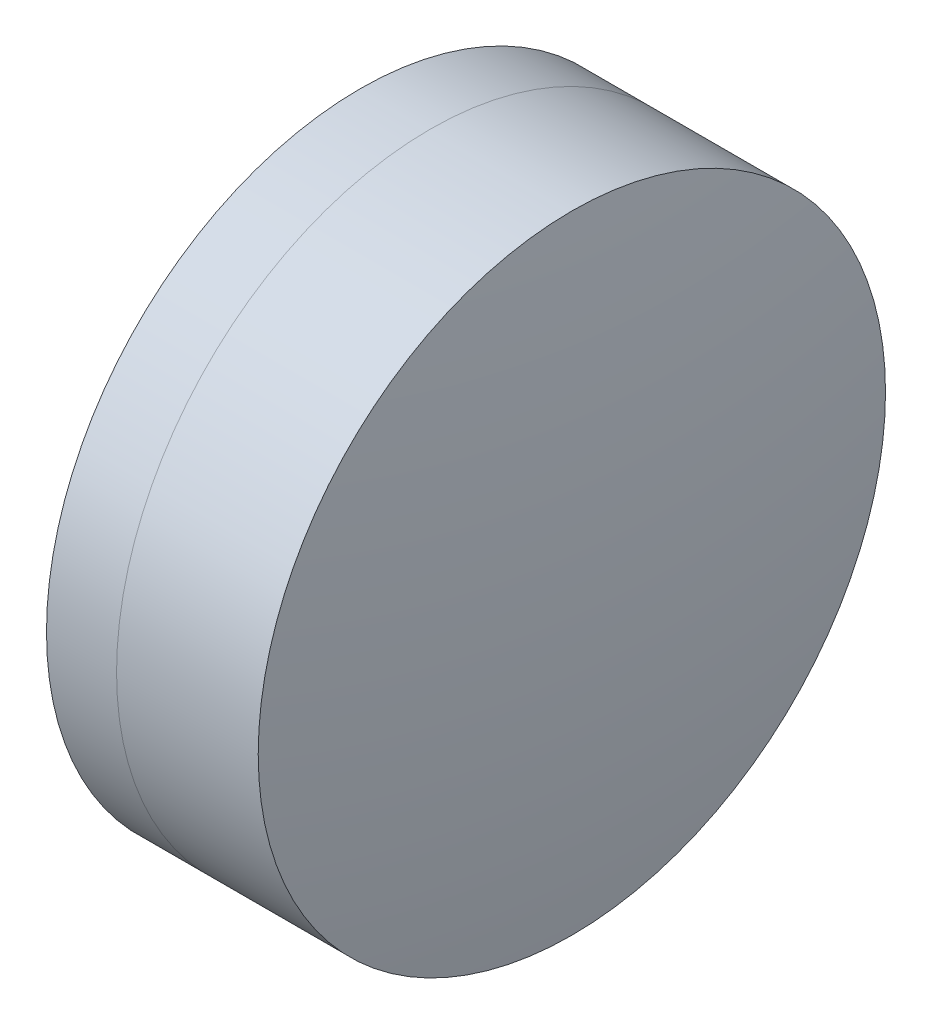
from build123d import *


with BuildPart() as part:
    # 草图1 one side → 旋转1 (revolve)
    with BuildSketch(Plane(origin=(0, 0, 0), x_dir=(1, 0, 0), z_dir=(0, 1, 0)), mode=Mode.PRIVATE) as revolve_1_sk:
        with BuildLine():
            ThreePointArc((2.605354895, 5), (2.014233192, 2.530995807), (1.815570679, 0))
            Line((1.815570679, 0), (4.865570679, 0))
            ThreePointArc((4.865570679, 0), (4.576106633, 2.564523008), (3.722280238, 5))
            Line((3.722280238, 5), (2.605354895, 5))
        make_face()
    revolve(revolve_1_sk.sketch.rotate(Axis((-9.702612178, 0, 0), (1, 0, 0)), 180), axis=Axis((-9.702612178, 0, 0), (1, 0, 0)))  # turned: the seam where the file's is


with BuildPart() as body_2:
    # 草图2 one side → 旋转3 (revolve)
    with BuildSketch(Plane(origin=(0, 0, 0), x_dir=(1, 0, 0), z_dir=(0, 1, 0)), mode=Mode.PRIVATE) as revolve_3_sk:
        with BuildLine():
            Line((5.980462903, 5), (3.722280238, 5))
            ThreePointArc((3.722280238, 5), (4.576106633, 2.564523008), (4.865570679, 0))
            Line((4.865570679, 0), (6.365570679, 0))
            ThreePointArc((6.365570679, 0), (6.26915137, 2.507404435), (5.980462903, 5))
        make_face()
    revolve(revolve_3_sk.sketch.rotate(Axis((-0.551919993, 0, 0), (1, 0, 0)), 180), axis=Axis((-0.551919993, 0, 0), (1, 0, 0)))  # turned: the seam where the file's is


solid = Compound([part.part, body_2.part])
